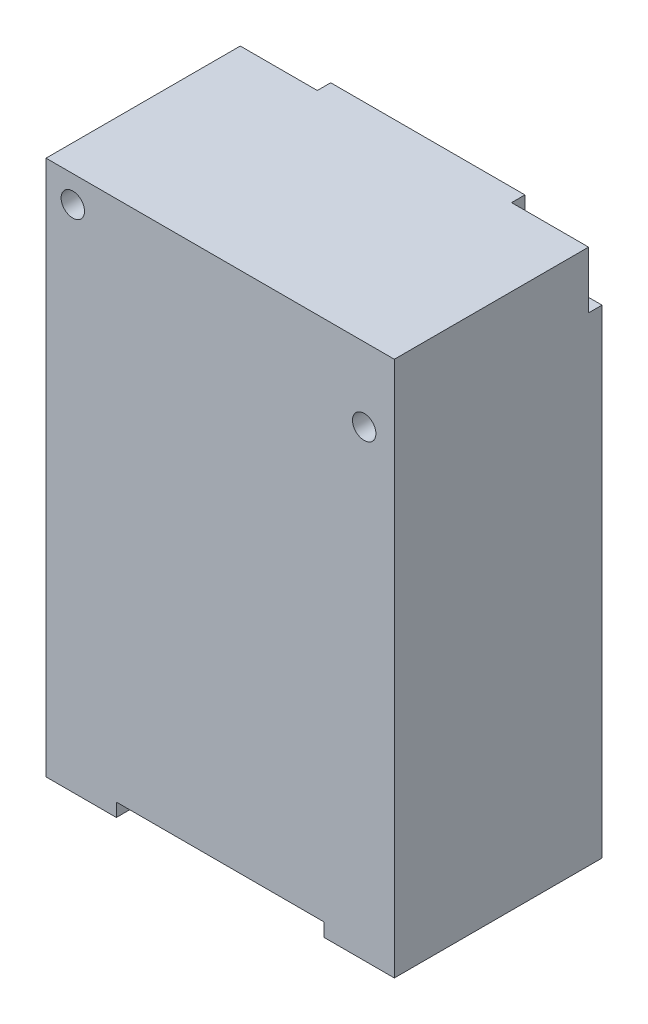
from build123d import *

# Parameters (mm, degrees)
ESQUISSE1_W             = 52
ESQUISSE1_H             = 80
ESQUISSE1_R             = 1.75
BOSS_EXTRU_1_DEPTH      = 31
ESQUISSE3_W             = 31
ESQUISSE3_H             = 15
ENL_V_MAT_EXTRU_3_DEPTH = 2
ESQUISSE1_2_R           = 1.75
BOSS_EXTRU_3_DEPTH      = 25
ESQUISSE2_W             = 11.5
ESQUISSE2_H             = 8.5
ENL_V_MAT_EXTRU_1_DEPTH = 2


with BuildPart() as part:
    # Esquisse1 → Boss.-Extru.1 (new body)
    with BuildSketch(Plane.XY):
        Rectangle(ESQUISSE1_W, ESQUISSE1_H)
        with Locations((21.5, 29)):
            Circle(ESQUISSE1_R, mode=Mode.SUBTRACT)
        with Locations((-22, 36)):
            Circle(ESQUISSE1_R, mode=Mode.SUBTRACT)
    extrude(amount=BOSS_EXTRU_1_DEPTH)

    # Esquisse3 → Enlèv. mat.-Extru.3 (cut)
    with BuildSketch(Plane.XZ.offset(40)):
        with Locations((0, 23.5)):
            Rectangle(ESQUISSE3_W, ESQUISSE3_H)
    extrude(amount=-ENL_V_MAT_EXTRU_3_DEPTH, mode=Mode.SUBTRACT)

    # Esquisse1_2 → Boss.-Extru.3 (add)
    with BuildSketch(Plane.XY):
        with Locations((21.5, 29)):
            Circle(ESQUISSE1_2_R)
        with Locations((-22, 36)):
            Circle(ESQUISSE1_2_R)
    extrude(amount=BOSS_EXTRU_3_DEPTH)

    # Esquisse2 → Enlèv. mat.-Extru.1 (cut)
    with BuildSketch(Plane(origin=(0, 0, 0), x_dir=(-1, 0, 0), z_dir=(0, 0, -1))):
        with Locations((-20.25, 35.75)):
            Rectangle(ESQUISSE2_W, ESQUISSE2_H)
        with Locations((20.25, 35.75)):
            Rectangle(ESQUISSE2_W, ESQUISSE2_H)
    extrude(amount=-ENL_V_MAT_EXTRU_1_DEPTH, mode=Mode.SUBTRACT)


solid = part.part
